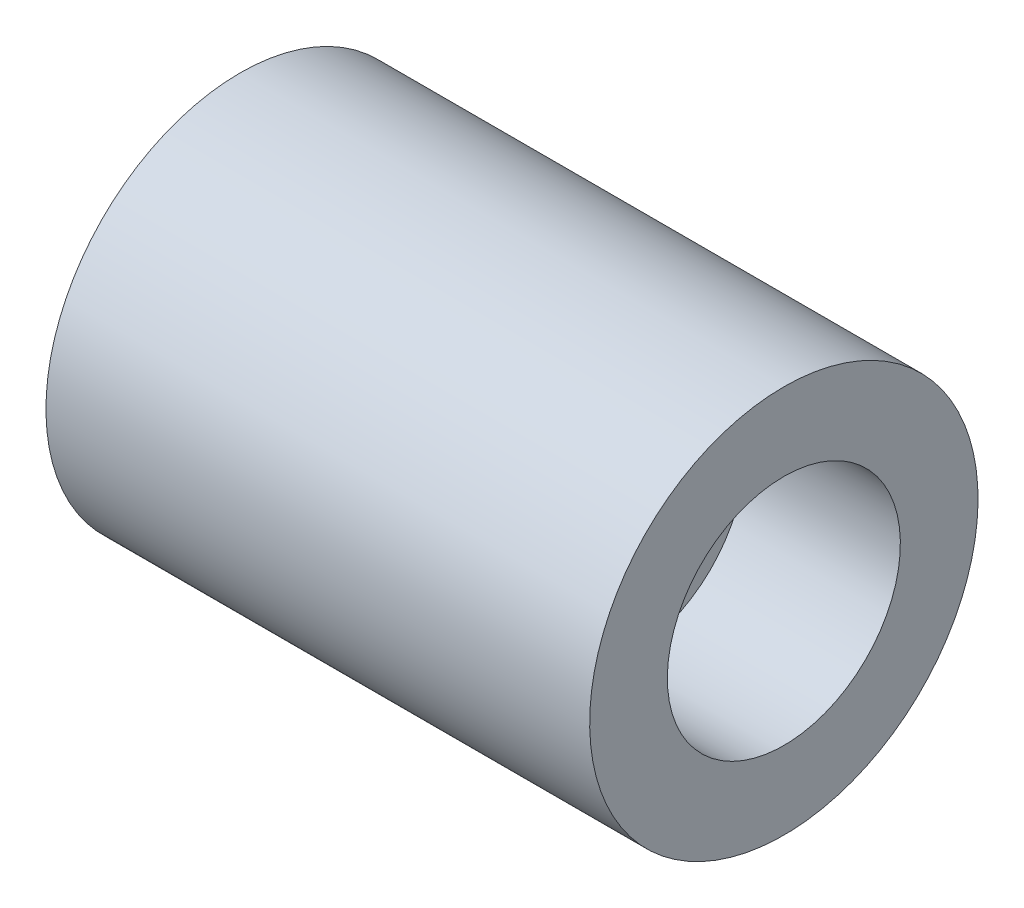
from build123d import *


with BuildPart() as part:
    # Croquis1 → Revolución1 (revolve)
    with BuildSketch(Plane.XY):
        Polygon((0, -50), (0, 0), (140, 0), (140, -20), (100, -20), (100, -40), (20, -40), (20, -50), align=None)
    revolve(axis=Axis((20, -50, 0), (-1, 0, 0)))


solid = part.part
